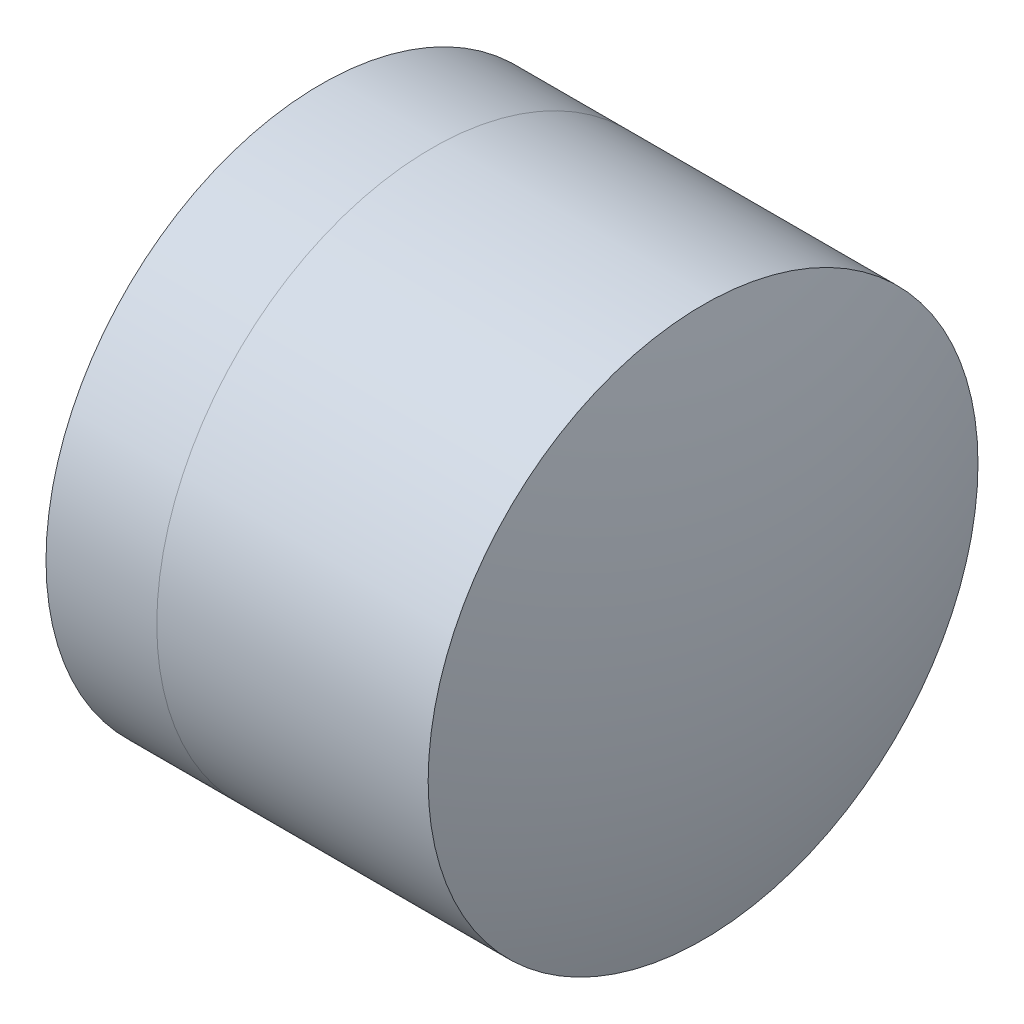
from build123d import *


with BuildPart() as part:
    # 草图1 one side → 旋转1 (revolve)
    with BuildSketch(Plane(origin=(0, 0, 0), x_dir=(1, 0, 0), z_dir=(0, 1, 0)), mode=Mode.PRIVATE) as revolve_1_sk:
        with BuildLine():
            ThreePointArc((1.133429728, 2), (0.76737148, 1.029630437), (0.642965311, 0))
            Line((0.642965311, 0), (2.842965311, 0))
            ThreePointArc((2.842965311, 0), (2.606558041, 1.097343316), (1.939278742, 2))
            Line((1.939278742, 2), (1.133429728, 2))
        make_face()
    revolve(revolve_1_sk.sketch.rotate(Axis((-0.816062176, 0, 0), (1, 0, 0)), 180), axis=Axis((-0.816062176, 0, 0), (1, 0, 0)))  # turned: the seam where the file's is


with BuildPart() as body_2:
    # 草图2 one side → 旋转3 (revolve)
    with BuildSketch(Plane(origin=(0, 0, 0), x_dir=(1, 0, 0), z_dir=(0, 1, 0)), mode=Mode.PRIVATE) as revolve_3_sk:
        with BuildLine():
            Line((3.913437502, 2), (1.939278742, 2))
            ThreePointArc((1.939278742, 2), (2.606558041, 1.097343316), (2.842965311, 0))
            Line((2.842965311, 0), (4.232965311, 0))
            ThreePointArc((4.232965311, 0), (4.152580026, 1.012681838), (3.913437502, 2))
        make_face()
    revolve(revolve_3_sk.sketch.rotate(Axis((-0.551919993, 0, 0), (1, 0, 0)), 180), axis=Axis((-0.551919993, 0, 0), (1, 0, 0)))  # turned: the seam where the file's is


solid = Compound([part.part, body_2.part])
